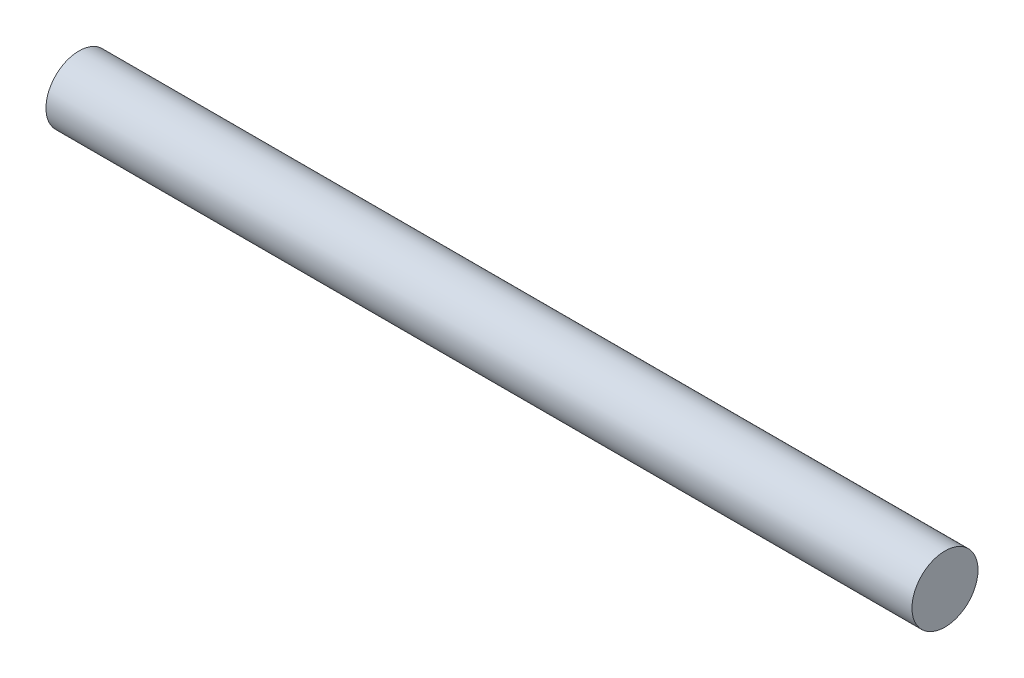
from build123d import *

# Parameters (mm, degrees)
EXTRUDE1_START = -177
SKETCH1_R      = 13.5
EXTRUDE1_DEPTH = 354


with BuildPart() as part:
    # Sketch1 → Extrude1 (new body)
    with BuildSketch(Plane(origin=(0, 0, 0), x_dir=(0, 0, -1), z_dir=(1, 0, 0)).offset(EXTRUDE1_START)):
        Circle(SKETCH1_R)
    extrude(amount=EXTRUDE1_DEPTH)


solid = part.part
